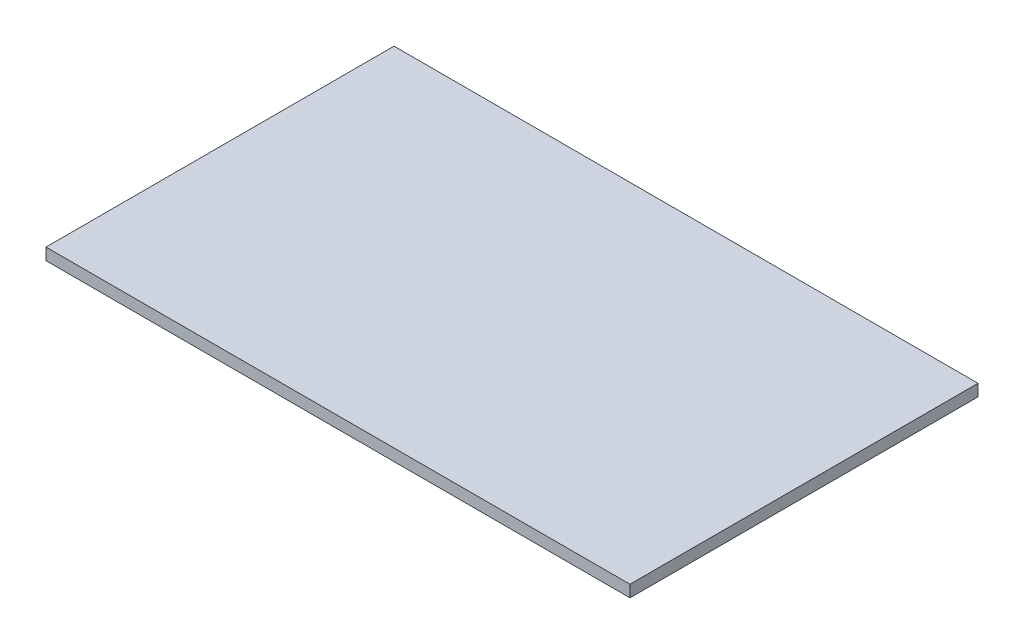
from build123d import *

# Parameters (mm, degrees)
CROQUIS1_W              = 495
CROQUIS1_H              = 295
SALIENTE_EXTRUIR1_DEPTH = 10


with BuildPart() as part:
    # Croquis1 → Saliente-Extruir1 (new body)
    with BuildSketch(Plane(origin=(0, 0, 0), x_dir=(1, 0, 0), z_dir=(0, 1, 0))):
        Rectangle(CROQUIS1_W, CROQUIS1_H)
    extrude(amount=SALIENTE_EXTRUIR1_DEPTH)


solid = part.part
